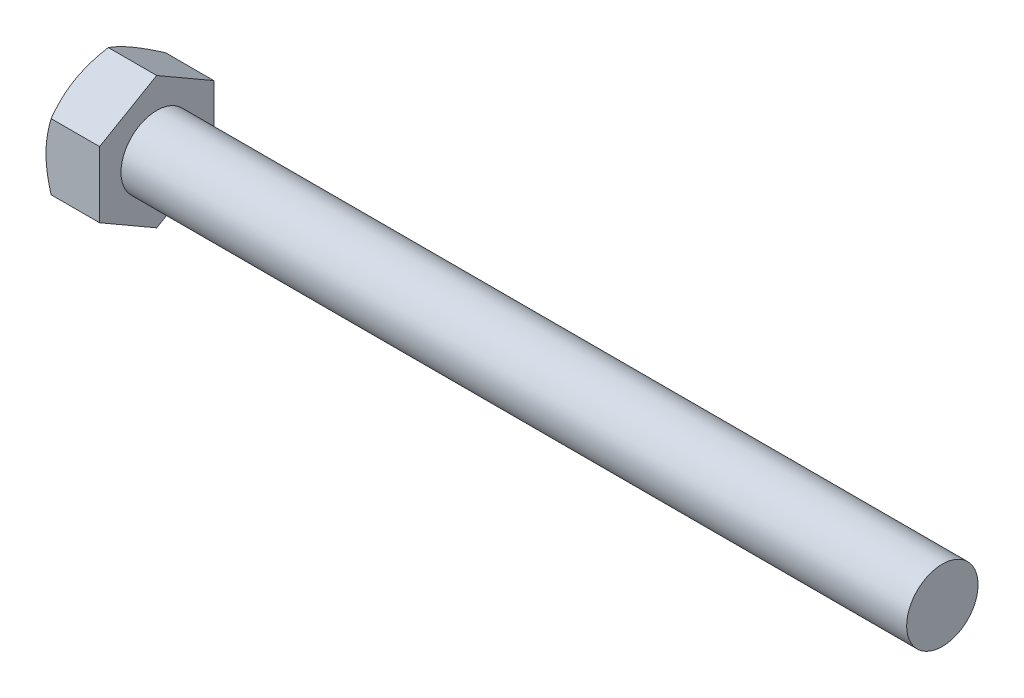
from build123d import *

# Parameters (mm, degrees)
SKETCH2_R     = 9.330254042
HEX_DIE_DEPTH = 7.5
SKETCH4_R     = 7
INDENT_DEPTH  = 0.9375


with BuildPart() as part:
    # BodySke → Base-Revolve (revolve)
    with BuildSketch(Plane.XY, mode=Mode.PRIVATE) as base_revolve_sk:
        Polygon((7.5, 5), (7.5, 9.237875289), (0.714687631, 9.237875289), (0, 8), (0, 0), (117.5, 0), (117.5, 5), align=None)
    revolve(base_revolve_sk.sketch.rotate(Axis((-25.4, 0, 0), (1, 0, 0)), 90), axis=Axis((-25.4, 0, 0), (1, 0, 0)))  # turned: the seam where the file's is

    # Sketch2 → Hex-Die (cut)
    with BuildSketch(Plane(origin=(0, 0, 0), x_dir=(0, 0, -1), z_dir=(1, 0, 0))):
        Circle(SKETCH2_R)
        Polygon((-8, 4.618802174), (0, 9.237604347), (8, 4.618802174), (8, -4.618802174), (0, -9.237604347), (-8, -4.618802174), align=None, mode=Mode.SUBTRACT)
    extrude(amount=HEX_DIE_DEPTH, mode=Mode.SUBTRACT)

    # Sketch4 → Indent (cut)
    with BuildSketch(Plane(origin=(0, 0, 0), x_dir=(0, 0, -1), z_dir=(1, 0, 0))):
        Circle(SKETCH4_R)
    extrude(amount=INDENT_DEPTH, mode=Mode.SUBTRACT)


solid = part.part
